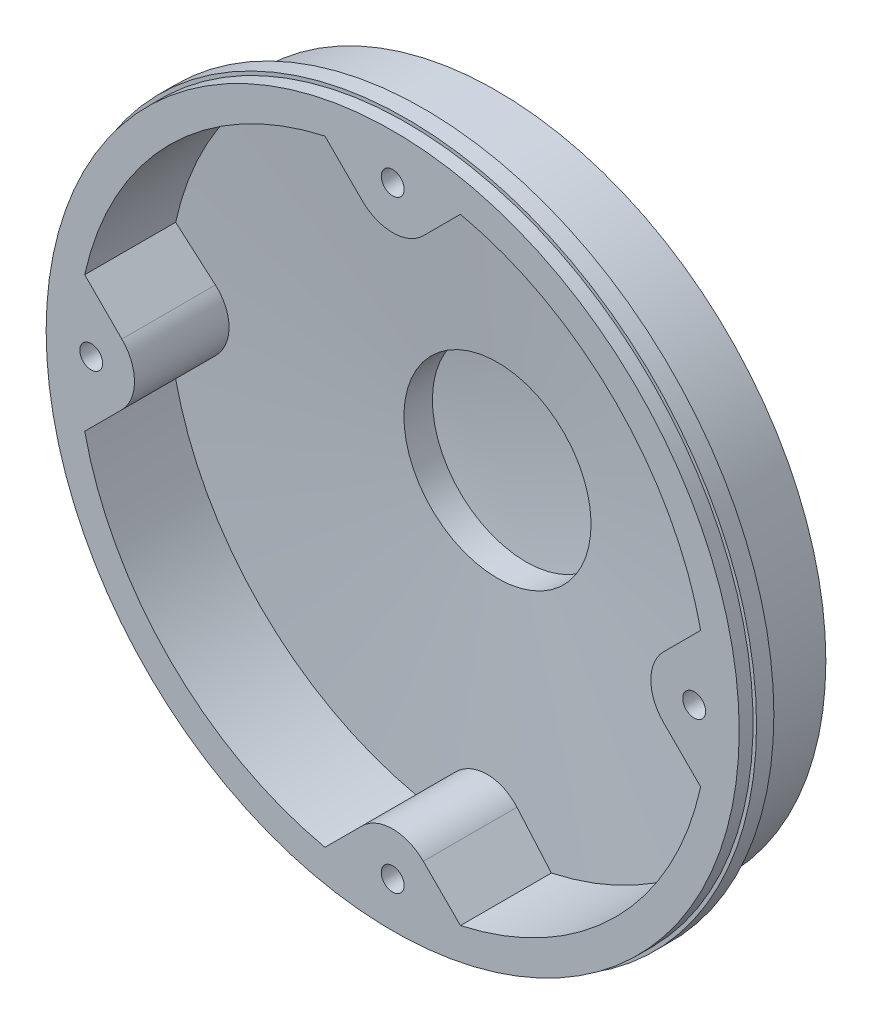
from build123d import *
from build123d.topology import SkipClean

# Parameters (mm, degrees)
BOSS_EXTRUDE1_REACH       = 76.165
CIRPATTERN1_COUNT         = 4
BOSS_EXTRUDE3_REACH       = 76.902
BOSS_EXTRUDE3_START       = 1
CIRPATTERN3_COUNT         = 16
M4X0_7_TAPPED_HOLE1_D     = 3.3
M4X0_7_TAPPED_HOLE1_DEPTH = 10
M4X0_7_TAPPED_HOLE1_TIP   = 0.991420021
SKETCH21_R                = 50
SKETCH21_R_2              = 1.65
BOSS_EXTRUDE4_DEPTH       = 2


with BuildPart() as part:
    # Sketch11 → Revolve1 (revolve)
    with BuildSketch(Plane(origin=(0, 0, 0), x_dir=(0, 0, -1), z_dir=(1, 0, 0)), mode=Mode.PRIVATE) as revolve1_sk:
        with BuildLine():
            Line((0, 0), (0, 50.5))
            Line((0, 50.5), (2.5, 50.5))
            Line((2.5, 50.5), (2.5, 47.5))
            Line((2.5, 47.5), (13, 47.5))
            Line((13, 47.5), (15, 15.5))
            Line((15, 15.5), (19, 15.5))
            ThreePointArc((19, 15.5), (19.749740394, 7.766112284), (20, 0))
            Line((20, 0), (0, 0))
        make_face()
    revolve(revolve1_sk.sketch.rotate(Axis((0, 0, 0), (0, 0, -1)), 90), axis=Axis((0, 0, 0), (0, 0, -1)))

    # Sketch13 → Cut-Revolve2 (revolve, cut)
    with BuildSketch(Plane(origin=(0, 0, 0), x_dir=(0, 0, -1), z_dir=(1, 0, 0)), mode=Mode.PRIVATE) as cut_revolve2_sk:
        with BuildLine():
            Line((0, 45.5), (11.121097557, 45.5))
            Line((11.121097557, 45.5), (13.121097557, 13.5))
            Line((13.121097557, 13.5), (17.229319501, 13.5))
            ThreePointArc((17.229319501, 13.5), (17.807173154, 6.760990098), (18, 0))
            Line((18, 0), (0, 0))
            Line((0, 0), (0, 45.5))
        make_face()
    revolve(cut_revolve2_sk.sketch.rotate(Axis((0, 0, 0), (0, 0, -1)), 180), axis=Axis((0, 0, 0), (0, 0, -1)), mode=Mode.SUBTRACT)

    # Boss-Extrude1: up to this cone (the profile starts inside it)
    boss_extrude1_end = Plane(origin=(0, 0, 0), z_dir=(0, 0, 1)).offset(-13.964846557) * Cone(1.6e-05, 5025.078535576, 314.067407474, align=(Align.CENTER, Align.CENTER, Align.MIN), mode=Mode.PRIVATE)
    # Sketch14 → Boss-Extrude1 (add, up to the surface)
    with BuildSketch(Plane.XY, mode=Mode.PRIVATE) as boss_extrude1_sk1:
        with BuildLine():
            Line((-39.080582618, 4.419417382), (-45.2729502, 10.611784965))
            ThreePointArc((-45.2729502, 10.611784965), (-46.5, 0), (-45.2729502, -10.611784965))
            Line((-45.2729502, -10.611784965), (-39.080582618, -4.419417382))
            ThreePointArc((-39.080582618, -4.419417382), (-37.25, 0), (-39.080582618, 4.419417382))
        make_face()
    boss_extrude1_tool1 = extrude(boss_extrude1_sk1.sketch, amount=-BOSS_EXTRUDE1_REACH, mode=Mode.PRIVATE) & boss_extrude1_end
    boss_extrude1 = boss_extrude1_tool1.solids().sort_by_distance((-42.66375, 0, 0))[0]
    add(boss_extrude1)

    # CirPattern1: Boss-Extrude1 ×4 about axis
    cirpattern1_axis = Axis((0, 0, 0), (0, 0, 1))
    for i in range(1, CIRPATTERN1_COUNT):
        add(boss_extrude1.rotate(cirpattern1_axis, i * 360 / CIRPATTERN1_COUNT))

    # Boss-Extrude3: up to this cone (the profile starts outside it)
    boss_extrude3_end = Plane(origin=(0, 0, -18), z_dir=(0, 0, 1)).offset(2.031251) * Cone(1.6e-05, 1205.932, 75.370749, align=(Align.CENTER, Align.CENTER, Align.MIN), mode=Mode.PRIVATE)
    # Sketch19 → Boss-Extrude3 (add, up to the surface)
    with BuildSketch(Plane.XY.offset(-19).offset(BOSS_EXTRUDE3_START), mode=Mode.PRIVATE) as boss_extrude3_sk1:
        with BuildLine():
            Line((0.5, 15.491933385), (0.25, 32.491933385))
            ThreePointArc((0.25, 32.491933385), (0.16904202, 34.998165246), (0, 37.5))
            ThreePointArc((0, 37.5), (-0.16904202, 34.998165246), (-0.25, 32.491933385))
            Line((-0.25, 32.491933385), (-0.5, 15.491933385))
            Line((-0.5, 15.491933385), (0.5, 15.491933385))
        make_face()
    boss_extrude3_tool1 = extrude(boss_extrude3_sk1.sketch, amount=BOSS_EXTRUDE3_REACH, mode=Mode.PRIVATE) - boss_extrude3_end
    boss_extrude3 = boss_extrude3_tool1.solids().sort_by_distance((0, 24.267183, -18))[0]
    add(boss_extrude3)

    # CirPattern3: Boss-Extrude3 ×16 about axis
    cirpattern3_axis = Axis((0, 0, 0), (0, 0, 1))
    for i in range(1, CIRPATTERN3_COUNT):
        add(boss_extrude3.rotate(cirpattern3_axis, i * 360 / CIRPATTERN3_COUNT))

    # Sketch20 → Cut-Revolve4 (revolve, cut)
    with BuildSketch(Plane(origin=(0, 0, 0), x_dir=(0, 0, -1), z_dir=(1, 0, 0))):
        Polygon((18, 15.5), (13.625, 37.5), (19, 37.5), (19, 15.5), align=None)
    revolve(axis=Axis((0, 0, 0), (0, 0, 1)), mode=Mode.SUBTRACT)

    # M4x0.7 Tapped Hole1
    with Locations(Plane.XY):
        with Locations((-43.5, 0), (0, 43.5), (43.5, 0), (0, -43.5)):
            Hole(M4X0_7_TAPPED_HOLE1_D / 2, depth=M4X0_7_TAPPED_HOLE1_DEPTH)
            with Locations((0, 0, -(M4X0_7_TAPPED_HOLE1_DEPTH + M4X0_7_TAPPED_HOLE1_TIP / 2))):  # 118° drill point
                Cone(0, M4X0_7_TAPPED_HOLE1_D / 2, M4X0_7_TAPPED_HOLE1_TIP, mode=Mode.SUBTRACT)

    # Sketch21 → Boss-Extrude4 (add)
    with SkipClean():  # the faces are left unmerged after this step: merging them gives an invalid solid
        with BuildSketch(Plane.XY):
            with Locations(Location((0, 0, 0), (0, 0, 180))):
                Circle(SKETCH21_R)
            with Locations((0, 43.5)):
                Circle(SKETCH21_R_2, mode=Mode.SUBTRACT)
            with Locations((-43.5, 0)):
                Circle(SKETCH21_R_2, mode=Mode.SUBTRACT)
            with Locations((43.5, 0)):
                Circle(SKETCH21_R_2, mode=Mode.SUBTRACT)
            with Locations((0, -43.5)):
                Circle(SKETCH21_R_2, mode=Mode.SUBTRACT)
            with BuildLine():
                Line((-9.776167577, 44.437332813), (-4.419417382, 39.080582618))
                ThreePointArc((-4.419417382, 39.080582618), (0, 37.25), (4.419417382, 39.080582618))
                Line((4.419417382, 39.080582618), (9.776167577, 44.437332813))
                ThreePointArc((9.776167577, 44.437332813), (32.173358544, 32.173358544), (44.437332813, 9.776167577))
                Line((44.437332813, 9.776167577), (39.080582618, 4.419417382))
                ThreePointArc((39.080582618, 4.419417382), (37.25, 0), (39.080582618, -4.419417382))
                Line((39.080582618, -4.419417382), (44.437332813, -9.776167577))
                ThreePointArc((44.437332813, -9.776167577), (32.173358544, -32.173358544), (9.776167577, -44.437332813))
                Line((9.776167577, -44.437332813), (4.419417382, -39.080582618))
                ThreePointArc((4.419417382, -39.080582618), (0, -37.25), (-4.419417382, -39.080582618))
                Line((-4.419417382, -39.080582618), (-9.776167577, -44.437332813))
                ThreePointArc((-9.776167577, -44.437332813), (-32.173358544, -32.173358544), (-44.437332813, -9.776167577))
                Line((-44.437332813, -9.776167577), (-39.080582618, -4.419417382))
                ThreePointArc((-39.080582618, -4.419417382), (-37.25, 0), (-39.080582618, 4.419417382))
                Line((-39.080582618, 4.419417382), (-44.437332813, 9.776167577))
                ThreePointArc((-44.437332813, 9.776167577), (-32.173358544, 32.173358544), (-9.776167577, 44.437332813))
            make_face(mode=Mode.SUBTRACT)
        extrude(amount=BOSS_EXTRUDE4_DEPTH)


solid = part.part
